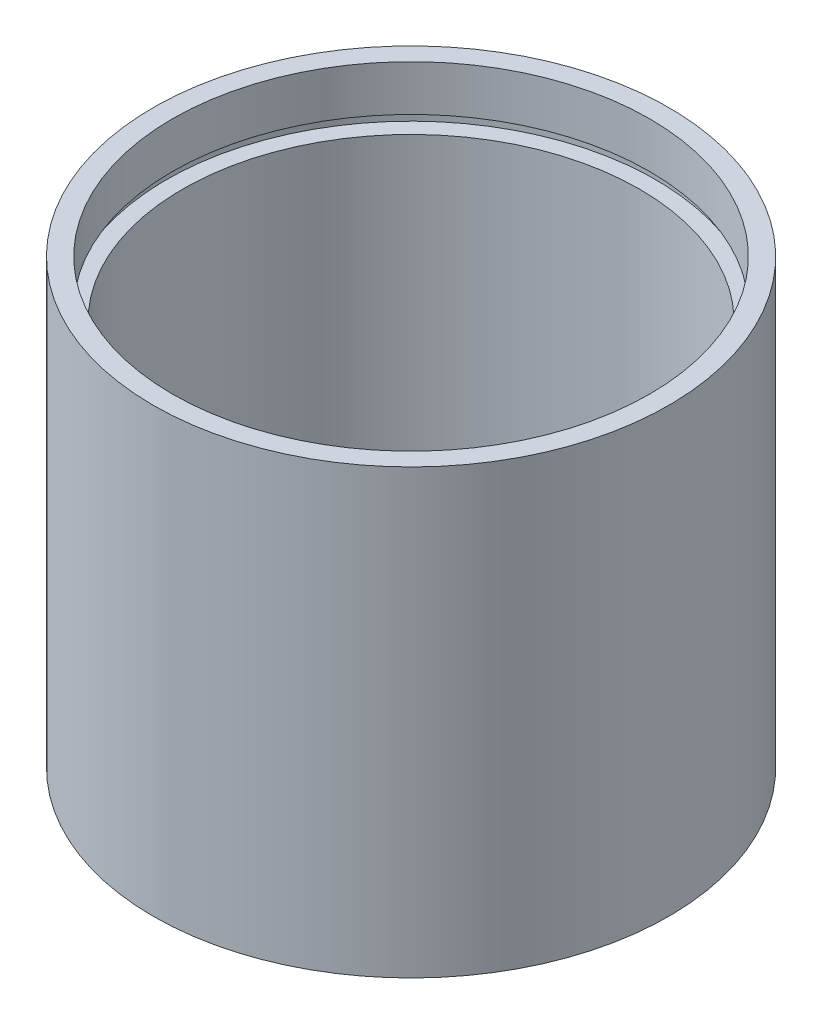
from build123d import *


with BuildPart() as part:
    # 草图1 → 旋转1 (revolve)
    with BuildSketch(Plane.XY, mode=Mode.PRIVATE) as revolve_1_sk:
        Polygon((25.4, 0), (25.4, 43.6), (23.5, 43.6), (23.5, 39.1), (24.1, 39.1), (24.1, 38.1), (22.5, 38.1), (22.5, 5.5), (24.1, 5.5), (24.1, 4.5), (23.5, 4.5), (23.5, 0), align=None)
    revolve(revolve_1_sk.sketch.rotate(Axis((0, 161.376166943, 0), (0, -1, 0)), 90), axis=Axis((0, 161.376166943, 0), (0, -1, 0)))  # turned: the seam where the file's is


solid = part.part
